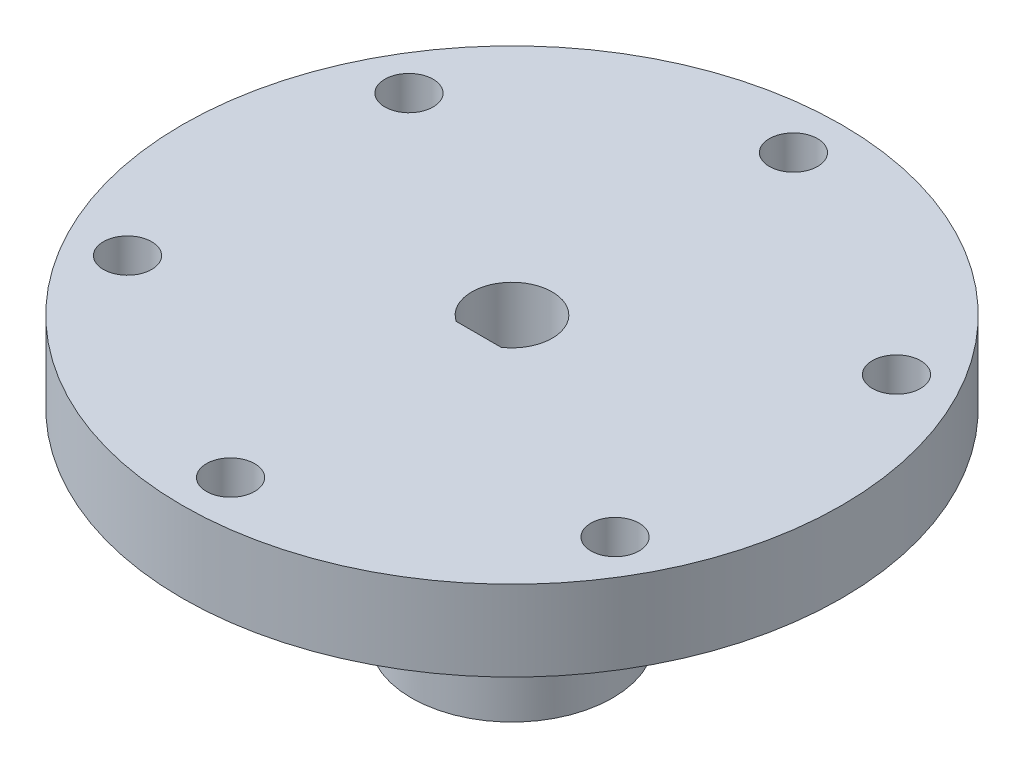
from build123d import *

# Parameters (mm, degrees)
SKETCH1_R           = 12.5
SKETCH1_R_2         = 5
BOSS_EXTRUDE1_DEPTH = 15
SKETCH2_R           = 41
SKETCH2_R_2         = 5
BOSS_EXTRUDE2_DEPTH = 20
SKETCH3_R           = 3
CUT_EXTRUDE1_DEPTH  = 36
BOSS_EXTRUDE3_DEPTH = 35
SKETCH5_R           = 1.5
CUT_EXTRUDE2_DEPTH  = 37.85
SKETCH6_R           = 41
SKETCH6_R_2         = 12.5
CUT_EXTRUDE3_DEPTH  = 10


with BuildPart() as part:
    # Sketch1 → Boss-Extrude1 (new body)
    with BuildSketch(Plane(origin=(0, 0, 0), x_dir=(1, 0, 0), z_dir=(0, 1, 0))):
        Circle(SKETCH1_R)
        Circle(SKETCH1_R_2, mode=Mode.SUBTRACT)
    extrude(amount=BOSS_EXTRUDE1_DEPTH)

    # Sketch2 → Boss-Extrude2 (add)
    with BuildSketch(Plane(origin=(0, 15, 0), x_dir=(1, 0, 0), z_dir=(0, 1, 0))):
        Circle(SKETCH2_R)
        Circle(SKETCH2_R_2, mode=Mode.SUBTRACT)
    extrude(amount=BOSS_EXTRUDE2_DEPTH)

    # Sketch3 → Cut-Extrude1 (cut, through all)
    with BuildSketch(Plane(origin=(0, 35, 0), x_dir=(1, 0, 0), z_dir=(0, 1, 0))):
        with Locations((0, 35)):
            Circle(SKETCH3_R)
        with Locations((30.310889132, 17.5)):
            Circle(SKETCH3_R)
        with Locations((30.310889132, -17.5)):
            Circle(SKETCH3_R)
        with Locations((0, -35)):
            Circle(SKETCH3_R)
        with Locations((-30.310889132, -17.5)):
            Circle(SKETCH3_R)
        with Locations((-30.310889132, 17.5)):
            Circle(SKETCH3_R)
    extrude(amount=-CUT_EXTRUDE1_DEPTH, mode=Mode.SUBTRACT)

    # Sketch4 → Boss-Extrude3 (add)
    with BuildSketch(Plane.XZ):
        with BuildLine():
            ThreePointArc((3.067854181, 4.15), (0, 5.160836103), (-3.067854181, 4.15))
            Line((-3.067854181, 4.15), (3.067854181, 4.15))
        make_face()
    extrude(amount=-BOSS_EXTRUDE3_DEPTH)

    # Sketch5 → Cut-Extrude2 (cut, through all)
    with BuildSketch(Plane(origin=(0, 0, 4.15), x_dir=(-1, 0, 0), z_dir=(0, 0, -1))):
        with Locations((0, 9)):
            Circle(SKETCH5_R)
    extrude(amount=-CUT_EXTRUDE2_DEPTH, mode=Mode.SUBTRACT)

    # Sketch6 → Cut-Extrude3 (cut)
    with BuildSketch(Plane.XZ.offset(-15)):
        Circle(SKETCH6_R)
        Circle(SKETCH6_R_2, mode=Mode.SUBTRACT)
    extrude(amount=-CUT_EXTRUDE3_DEPTH, mode=Mode.SUBTRACT)


solid = part.part
